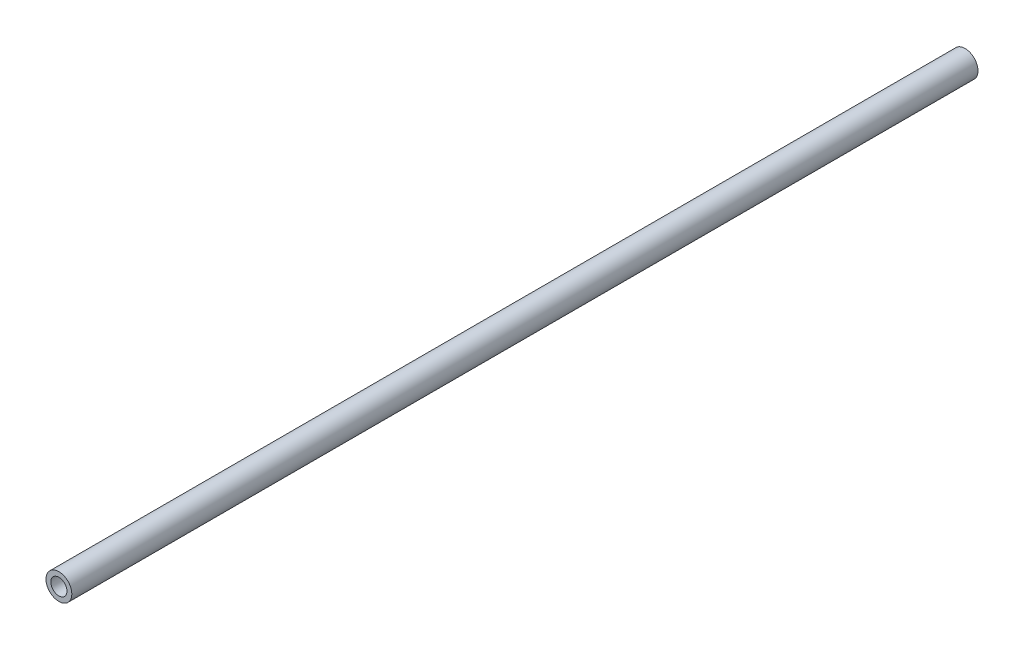
from build123d import *

# Parameters (mm, degrees)
SKETCH1_R           = 8.55
SKETCH1_R_2         = 5.35
BOSS_EXTRUDE1_DEPTH = 600


with BuildPart() as part:
    # Sketch1 → Boss-Extrude1 (new body)
    with BuildSketch(Plane.XY):
        Circle(SKETCH1_R)
        Circle(SKETCH1_R_2, mode=Mode.SUBTRACT)
    extrude(amount=-BOSS_EXTRUDE1_DEPTH)


solid = part.part
